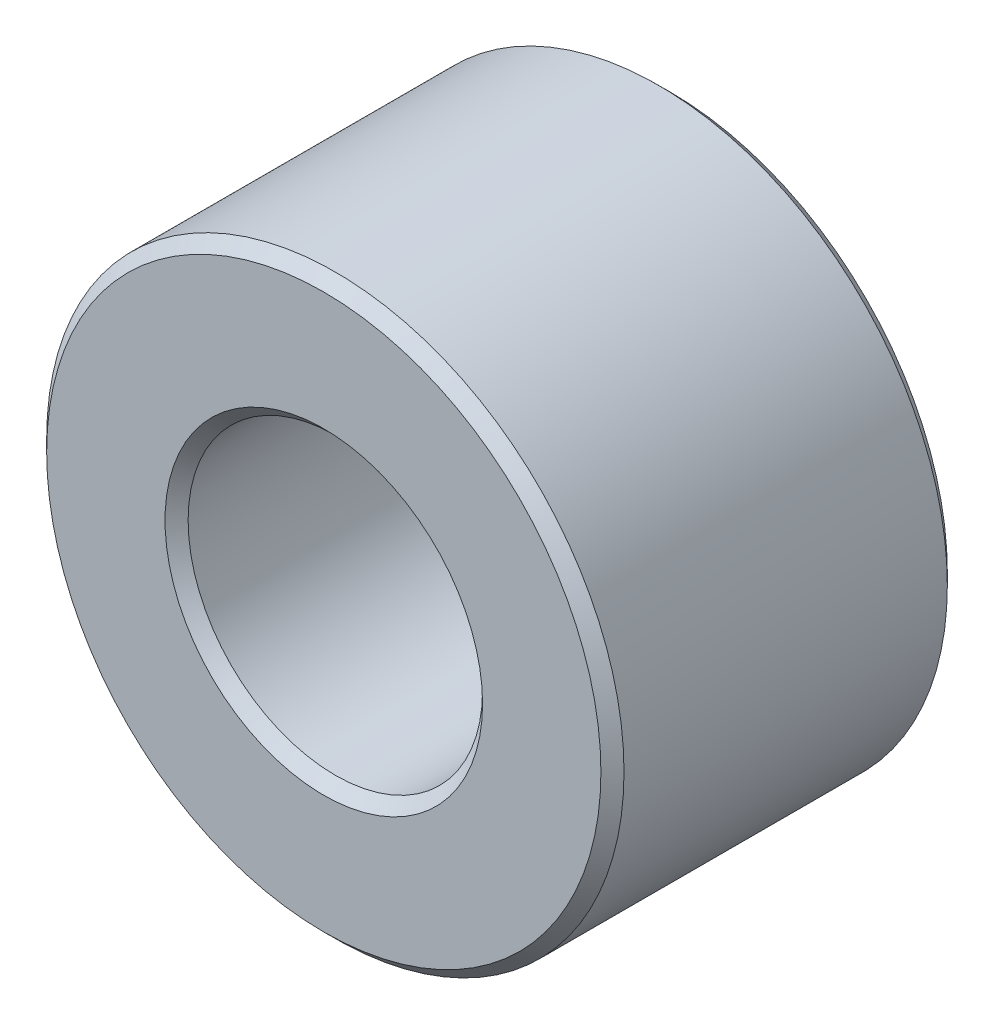
from build123d import *

# Parameters (mm, degrees)
SKETCH1_R           = 5
SKETCH1_R_2         = 2.55
BOSS_EXTRUDE1_DEPTH = 6
CHAMFER1_SIZE       = 0.2


with BuildPart() as part:
    # Sketch1 → Boss-Extrude1 (new body)
    with BuildSketch(Plane.XY):
        Circle(SKETCH1_R)
        Circle(SKETCH1_R_2, mode=Mode.SUBTRACT)
    extrude(amount=BOSS_EXTRUDE1_DEPTH)

    # Chamfer1
    chamfer1_edges = [part.edges().sort_by_distance(p)[0] for p in [
        (-5, 0, 0),
        (-5, 0, 6),
        (-2.55, 0, 0),
        (-2.55, 0, 6),
    ]]
    chamfer(chamfer1_edges, length=CHAMFER1_SIZE)


solid = part.part
